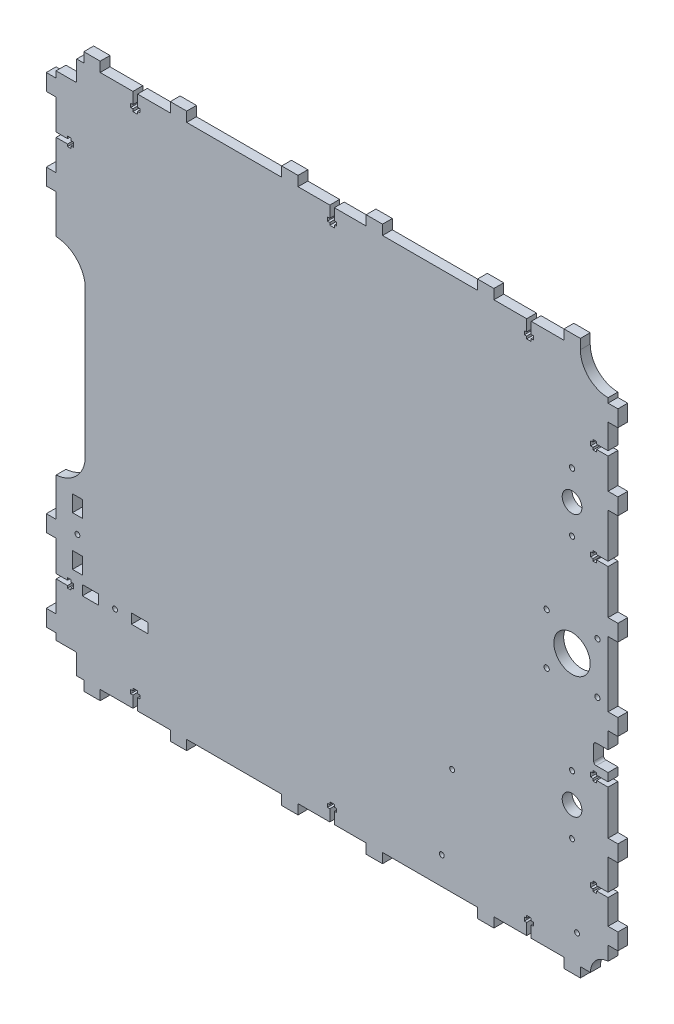
from build123d import *

# Parameters (mm, degrees)
SKETCH_1_R      = 6
SKETCH_1_R_2    = 1.6
SKETCH_1_R_3    = 1.55
SKETCH_1_R_4    = 11.1
SKETCH_1_R_5    = 1.5
SKETCH_1_W      = 10
SKETCH_1_H      = 6
SKETCH_1_W_2    = 6
SKETCH_1_H_2    = 10
EXTRUDE_1_DEPTH = 6


with BuildPart() as part:
    # Sketch 1 (on Front Plane) → Extrude 1 (new body)
    with BuildSketch(Plane.XY):
        with BuildLine():
            Line((168.199310706, -52.298122462), (168.199310706, -57.218125343))
            Line((168.199310706, -57.218125343), (161.199309499, -57.218125343))
            Line((161.199309499, -57.218125343), (161.199309499, -55.815811247))
            Line((161.199309499, -55.815811247), (158.998486916, -55.815811247))
            Line((158.998486916, -55.815811247), (158.999308988, -57.215692211))
            Line((158.999308988, -57.215692211), (157.499309247, -57.216573077))
            Line((157.499309247, -57.216573077), (157.500952992, -60.015655883))
            Line((157.500952992, -60.015655883), (159.000952734, -60.014775017))
            Line((159.000952734, -60.014775017), (159.001775414, -61.415692272))
            Line((159.001775414, -61.415692272), (161.202727499, -61.415745636))
            Line((161.202727499, -61.415745636), (161.202286063, -60.018125343))
            Line((161.202286063, -60.018125343), (168.199310706, -60.018125343))
            Line((168.199310706, -60.018125343), (168.199310706, -87.018125343))
            Line((168.199310706, -87.018125343), (174.199310706, -87.018125343))
            Line((174.199310706, -87.018125343), (174.199310706, -97.018125338))
            Line((174.199310706, -97.018125338), (168.199310706, -97.018125338))
            Line((168.199310706, -97.018125338), (168.199310706, -115.618125338))
            Line((168.199310706, -115.618125338), (161.199752595, -115.618125338))
            Line((161.199752595, -115.618125338), (161.199752595, -114.216834131))
            Line((161.199752595, -114.216834131), (158.998486916, -114.216834131))
            Line((158.998486916, -114.216834131), (158.999308988, -115.616715096))
            Line((158.999308988, -115.616715096), (157.499309247, -115.617595962))
            Line((157.499309247, -115.617595962), (157.500952992, -118.416678768))
            Line((157.500952992, -118.416678768), (159.000952734, -118.415797902))
            Line((159.000952734, -118.415797902), (159.001775414, -119.816715157))
            Line((159.001775414, -119.816715157), (161.202113772, -119.816768506))
            Line((161.202113772, -119.816768506), (161.201876481, -118.418125338))
            Line((161.201876481, -118.418125338), (168.199310706, -118.418125338))
            Line((168.199310706, -118.418125338), (168.199310706, -133.598125338))
            Line((168.199310706, -133.598125338), (174.199310706, -133.598125338))
            Line((174.199310706, -133.598125338), (174.199310706, -143.598125338))
            Line((174.199310706, -143.598125338), (168.199310706, -143.598125338))
            Line((168.199310706, -143.598125338), (168.199310706, -152.12715677))
            ThreePointArc((168.199310706, -152.12715677), (160.572403694, -155.612835394), (157.456488656, -163.398125338))
            Line((157.456488656, -163.398125338), (151.289310706, -163.398125338))
            Line((151.289310706, -163.398125338), (151.289310706, -169.398125338))
            Line((151.289310706, -169.398125338), (141.289310706, -169.398125338))
            Line((141.289310706, -169.398125338), (141.289310706, -163.398125338))
            Line((141.289310706, -163.398125338), (121.289310706, -163.398125338))
            Line((121.289310706, -163.398125338), (121.289310706, -156.4006243))
            Line((121.289310706, -156.4006243), (122.688120776, -156.400828255))
            Line((122.688120776, -156.400828255), (122.68806743, -154.200590047))
            Line((122.68806743, -154.200590047), (121.287150175, -154.199767366))
            Line((121.287150175, -154.199767366), (121.288031041, -152.699767026))
            Line((121.288031041, -152.699767026), (118.489968512, -152.69812388))
            Line((118.489968512, -152.69812388), (118.489087646, -154.198123621))
            Line((118.489087646, -154.198123621), (117.089206681, -154.197301549))
            Line((117.089206681, -154.197301549), (117.089206681, -156.398124131))
            Line((117.089206681, -156.398124131), (118.489310706, -156.398124131))
            Line((118.489310706, -156.398124131), (118.489310706, -163.398125338))
            Line((118.489310706, -163.398125338), (98.489310706, -163.398125338))
            Line((98.489310706, -163.398125338), (98.489310706, -169.398125338))
            Line((98.489310706, -169.398125338), (88.489310706, -169.398125338))
            Line((88.489310706, -169.398125338), (88.489310706, -163.398125338))
            Line((88.489310706, -163.398125338), (30.489310706, -163.398125338))
            Line((30.489310706, -163.398125338), (30.489310706, -169.398125338))
            Line((30.489310706, -169.398125338), (20.489310706, -169.398125338))
            Line((20.489310706, -169.398125338), (20.489310706, -163.398125338))
            Line((20.489310706, -163.398125338), (1.099310706, -163.398125338))
            Line((1.099310706, -163.398125338), (1.099310706, -156.4006243))
            Line((1.099310706, -156.4006243), (2.498120776, -156.400828255))
            Line((2.498120776, -156.400828255), (2.49806743, -154.200590047))
            Line((2.49806743, -154.200590047), (1.097150175, -154.199767366))
            Line((1.097150175, -154.199767366), (1.098031041, -152.699767026))
            Line((1.098031041, -152.699767026), (-1.700031488, -152.69812388))
            Line((-1.700031488, -152.69812388), (-1.700912354, -154.198123621))
            Line((-1.700912354, -154.198123621), (-3.100793319, -154.197301549))
            Line((-3.100793319, -154.197301549), (-3.100793319, -156.398124131))
            Line((-3.100793319, -156.398124131), (-1.700689294, -156.398124131))
            Line((-1.700689294, -156.398124131), (-1.700689294, -163.398125338))
            Line((-1.700689294, -163.398125338), (-21.090689294, -163.398125338))
            Line((-21.090689294, -163.398125338), (-21.090689294, -169.398125338))
            Line((-21.090689294, -169.398125338), (-31.090689294, -169.398125338))
            Line((-31.090689294, -169.398125338), (-31.090689294, -163.398125338))
            Line((-31.090689294, -163.398125338), (-89.090689294, -163.398125338))
            Line((-89.090689294, -163.398125338), (-89.090689294, -169.398125338))
            Line((-89.090689294, -169.398125338), (-99.090689294, -169.398125338))
            Line((-99.090689294, -169.398125338), (-99.090689294, -163.398125338))
            Line((-99.090689294, -163.398125338), (-119.090689294, -163.398125338))
            Line((-119.090689294, -163.398125338), (-119.090689294, -156.4006243))
            Line((-119.090689294, -156.4006243), (-117.691879224, -156.400828255))
            Line((-117.691879224, -156.400828255), (-117.69193257, -154.200590047))
            Line((-117.69193257, -154.200590047), (-119.092849825, -154.199767366))
            Line((-119.092849825, -154.199767366), (-119.091968959, -152.699767026))
            Line((-119.091968959, -152.699767026), (-121.890031488, -152.69812388))
            Line((-121.890031488, -152.69812388), (-121.890912354, -154.198123621))
            Line((-121.890912354, -154.198123621), (-123.290793319, -154.197301549))
            Line((-123.290793319, -154.197301549), (-123.290793319, -156.398124131))
            Line((-123.290793319, -156.398124131), (-121.890689294, -156.398124131))
            Line((-121.890689294, -156.398124131), (-121.890689294, -163.398125338))
            Line((-121.890689294, -163.398125338), (-141.890689294, -163.398125338))
            Line((-141.890689294, -163.398125338), (-141.890689294, -169.398125338))
            Line((-141.890689294, -169.398125338), (-151.890689294, -169.398125338))
            Line((-151.890689294, -169.398125338), (-151.890689294, -163.398125338))
            Line((-151.890689294, -163.398125338), (-156.195092631, -163.398125338))
            Line((-156.195092631, -163.398125338), (-156.195092631, -151.950559202))
            ThreePointArc((-156.195092631, -151.950559202), (-156.443252823, -151.291213387), (-157.064566439, -150.959114341))
            Line((-157.064566439, -150.959114341), (-157.195092631, -150.950559202))
            Line((-157.195092631, -150.950559202), (-168.800689294, -150.950559202))
            Line((-168.800689294, -150.950559202), (-168.800689294, -146.938125338))
            Line((-168.800689294, -146.938125338), (-174.800689294, -146.938125338))
            Line((-174.800689294, -146.938125338), (-174.800689294, -136.938125338))
            Line((-174.800689294, -136.938125338), (-168.800689294, -136.938125338))
            Line((-168.800689294, -136.938125338), (-168.800689294, -118.438125338))
            Line((-168.800689294, -118.438125338), (-161.800688087, -118.438125338))
            Line((-161.800688087, -118.438125338), (-161.800688087, -119.838229363))
            Line((-161.800688087, -119.838229363), (-159.599865505, -119.838229363))
            Line((-159.599865505, -119.838229363), (-159.600686983, -118.439360374))
            Line((-159.600686983, -118.439360374), (-158.100196827, -118.43847922))
            Line((-158.100196827, -118.43847922), (-158.095498836, -115.637580558))
            Line((-158.095498836, -115.637580558), (-159.602331088, -115.638721675))
            Line((-159.602331088, -115.638721675), (-159.603391996, -114.237804581))
            Line((-159.603391996, -114.237804581), (-161.803392384, -114.238125353))
            Line((-161.803392384, -114.238125353), (-161.803188256, -115.638125338))
            Line((-161.803188256, -115.638125338), (-168.800689294, -115.638125338))
            Line((-168.800689294, -115.638125338), (-168.800689294, -96.918125338))
            Line((-168.800689294, -96.918125338), (-174.800689294, -96.918125338))
            Line((-174.800689294, -96.918125338), (-174.800689294, -86.918125338))
            Line((-174.800689294, -86.918125338), (-168.800689294, -86.918125338))
            Line((-168.800689294, -86.918125338), (-168.800689294, -63.480258903))
            ThreePointArc((-168.800689294, -63.480258903), (-157.388702527, -58.725695754), (-151.244839154, -47.997589884))
            Line((-151.244839154, -47.997589884), (-151.272354325, 47.500944109))
            ThreePointArc((-151.272354325, 47.500944109), (-157.419219349, 58.082787741), (-168.800689294, 62.579620646))
            Line((-168.800689294, 62.579620646), (-168.800689294, 86.321874662))
            Line((-168.800689294, 86.321874662), (-174.800689294, 86.321874662))
            Line((-174.800689294, 86.321874662), (-174.800689294, 96.321874662))
            Line((-174.800689294, 96.321874662), (-168.800689294, 96.321874662))
            Line((-168.800689294, 96.321874662), (-168.800689294, 115.041874662))
            Line((-168.800689294, 115.041874662), (-161.800688087, 115.041874662))
            Line((-161.800688087, 115.041874662), (-161.800688087, 113.641770637))
            Line((-161.800688087, 113.641770637), (-159.599865505, 113.641770637))
            Line((-159.599865505, 113.641770637), (-159.600687577, 115.041651602))
            Line((-159.600687577, 115.041651602), (-158.100210407, 115.042532748))
            Line((-158.100210407, 115.042532748), (-158.102330745, 117.842414269))
            Line((-158.102330745, 117.842414269), (-159.602331088, 117.841278325))
            Line((-159.602331088, 117.841278325), (-159.603391996, 119.242195419))
            Line((-159.603391996, 119.242195419), (-161.803392384, 119.241874647))
            Line((-161.803392384, 119.241874647), (-161.803188256, 117.841874662))
            Line((-161.803188256, 117.841874662), (-168.800689294, 117.841874662))
            Line((-168.800689294, 117.841874662), (-168.800689294, 136.341874662))
            Line((-168.800689294, 136.341874662), (-174.800689294, 136.341874662))
            Line((-174.800689294, 136.341874662), (-174.800689294, 146.341874662))
            Line((-174.800689294, 146.341874662), (-168.800689294, 146.341874662))
            Line((-168.800689294, 146.341874662), (-168.800689294, 150.22196022))
            Line((-168.800689294, 150.22196022), (-157.195092631, 150.22196022))
            ThreePointArc((-157.195092631, 150.22196022), (-156.48798585, 150.514853439), (-156.195092631, 151.22196022))
            Line((-156.195092631, 151.22196022), (-156.195092631, 162.801874662))
            Line((-156.195092631, 162.801874662), (-151.890689294, 162.801874662))
            Line((-151.890689294, 162.801874662), (-151.890689294, 168.801874662))
            Line((-151.890689294, 168.801874662), (-141.890689294, 168.801874662))
            Line((-141.890689294, 168.801874662), (-141.890689294, 162.801874662))
            Line((-141.890689294, 162.801874662), (-121.890689294, 162.801874662))
            Line((-121.890689294, 162.801874662), (-121.890689294, 155.801873455))
            Line((-121.890689294, 155.801873455), (-123.290793319, 155.801873455))
            Line((-123.290793319, 155.801873455), (-123.290793319, 153.601050872))
            Line((-123.290793319, 153.601050872), (-121.890912354, 153.601872944))
            Line((-121.890912354, 153.601872944), (-121.890031488, 152.101873203))
            Line((-121.890031488, 152.101873203), (-119.091968959, 152.103516349))
            Line((-119.091968959, 152.103516349), (-119.092849825, 153.60351669))
            Line((-119.092849825, 153.60351669), (-117.69193257, 153.60433937))
            Line((-117.69193257, 153.60433937), (-117.691879224, 155.804577578))
            Line((-117.691879224, 155.804577578), (-119.090689294, 155.804373623))
            Line((-119.090689294, 155.804373623), (-119.090689294, 162.801874662))
            Line((-119.090689294, 162.801874662), (-99.090689294, 162.801874662))
            Line((-99.090689294, 162.801874662), (-99.090689294, 168.801874662))
            Line((-99.090689294, 168.801874662), (-89.090689294, 168.801874662))
            Line((-89.090689294, 168.801874662), (-89.090689294, 162.801874662))
            Line((-89.090689294, 162.801874662), (-31.090689294, 162.801874662))
            Line((-31.090689294, 162.801874662), (-31.090689294, 168.801874662))
            Line((-31.090689294, 168.801874662), (-21.090689294, 168.801874662))
            Line((-21.090689294, 168.801874662), (-21.090689294, 162.801874662))
            Line((-21.090689294, 162.801874662), (-1.700689294, 162.801874662))
            Line((-1.700689294, 162.801874662), (-1.700689294, 155.801873455))
            Line((-1.700689294, 155.801873455), (-3.100793319, 155.801873455))
            Line((-3.100793319, 155.801873455), (-3.100793319, 153.601050872))
            Line((-3.100793319, 153.601050872), (-1.700912354, 153.601872944))
            Line((-1.700912354, 153.601872944), (-1.700031488, 152.101873203))
            Line((-1.700031488, 152.101873203), (1.098031041, 152.103516349))
            Line((1.098031041, 152.103516349), (1.097150175, 153.60351669))
            Line((1.097150175, 153.60351669), (2.49806743, 153.60433937))
            Line((2.49806743, 153.60433937), (2.498120776, 155.804577578))
            Line((2.498120776, 155.804577578), (1.099310706, 155.804373623))
            Line((1.099310706, 155.804373623), (1.099310706, 162.801874662))
            Line((1.099310706, 162.801874662), (20.489310706, 162.801874662))
            Line((20.489310706, 162.801874662), (20.489310706, 168.801874662))
            Line((20.489310706, 168.801874662), (30.489310706, 168.801874662))
            Line((30.489310706, 168.801874662), (30.489310706, 162.801874662))
            Line((30.489310706, 162.801874662), (88.489310706, 162.801874662))
            Line((88.489310706, 162.801874662), (88.489310706, 168.801874662))
            Line((88.489310706, 168.801874662), (98.489310706, 168.801874662))
            Line((98.489310706, 168.801874662), (98.489310706, 162.801874662))
            Line((98.489310706, 162.801874662), (118.489310706, 162.801874662))
            Line((118.489310706, 162.801874662), (118.489310706, 155.801873455))
            Line((118.489310706, 155.801873455), (117.089206681, 155.801873455))
            Line((117.089206681, 155.801873455), (117.089206681, 153.601050872))
            Line((117.089206681, 153.601050872), (118.489087646, 153.601872944))
            Line((118.489087646, 153.601872944), (118.489968512, 152.101873203))
            Line((118.489968512, 152.101873203), (121.288031041, 152.103516349))
            Line((121.288031041, 152.103516349), (121.287150175, 153.60351669))
            Line((121.287150175, 153.60351669), (122.68806743, 153.60433937))
            Line((122.68806743, 153.60433937), (122.688120776, 155.804577578))
            Line((122.688120776, 155.804577578), (121.289310706, 155.804373623))
            Line((121.289310706, 155.804373623), (121.289310706, 162.801874662))
            Line((121.289310706, 162.801874662), (141.289310706, 162.801874662))
            Line((141.289310706, 162.801874662), (141.289310706, 168.801874662))
            Line((141.289310706, 168.801874662), (151.289310706, 168.801874662))
            Line((151.289310706, 168.801874662), (151.289310706, 162.801874662))
            ThreePointArc((151.289310706, 162.801874662), (156.242135036, 150.844698992), (168.199310706, 145.891874662))
            Line((168.199310706, 145.891874662), (168.199310706, 143.001874662))
            Line((168.199310706, 143.001874662), (174.199310706, 143.001874662))
            Line((174.199310706, 143.001874662), (174.199310706, 133.001874662))
            Line((174.199310706, 133.001874662), (168.199310706, 133.001874662))
            Line((168.199310706, 133.001874662), (168.199310706, 117.821874662))
            Line((168.199310706, 117.821874662), (161.198884876, 117.821874662))
            Line((161.198884876, 117.821874662), (161.198672593, 119.221937544))
            Line((161.198672593, 119.221937544), (158.997850029, 119.221603846))
            Line((158.997850029, 119.221603846), (158.998884357, 117.821723022))
            Line((158.998884357, 117.821723022), (157.498884767, 117.820614719))
            Line((157.498884767, 117.820614719), (157.500952921, 115.021532194))
            Line((157.500952921, 115.021532194), (159.000952512, 115.022640497))
            Line((159.000952512, 115.022640497), (159.001987605, 113.621723383))
            Line((159.001987605, 113.621723383), (161.202013777, 113.622003619))
            Line((161.202013777, 113.622003619), (161.201809668, 115.021874662))
            Line((161.201809668, 115.021874662), (168.199310706, 115.021874662))
            Line((168.199310706, 115.021874662), (168.199310706, 96.421874662))
            Line((168.199310706, 96.421874662), (174.199310706, 96.421874662))
            Line((174.199310706, 96.421874662), (174.199310706, 86.421874662))
            Line((174.199310706, 86.421874662), (168.199310706, 86.421874662))
            Line((168.199310706, 86.421874662), (168.199310706, 59.421874662))
            Line((168.199310706, 59.421874662), (161.199309232, 59.421874662))
            Line((161.199309232, 59.421874662), (161.199309232, 60.476838077))
            Line((161.199309232, 60.476838077), (158.998486738, 60.476838077))
            Line((158.998486738, 60.476838077), (158.99930881, 59.076957113))
            Line((158.99930881, 59.076957113), (157.499309069, 59.076076247))
            Line((157.499309069, 59.076076247), (157.500952814, 56.276993441))
            Line((157.500952814, 56.276993441), (159.000952556, 56.277874307))
            Line((159.000952556, 56.277874307), (159.001775236, 54.876957052))
            Line((159.001775236, 54.876957052), (161.202064095, 54.876903704))
            Line((161.202064095, 54.876903704), (161.201809668, 56.621874662))
            Line((161.201809668, 56.621874662), (168.199310706, 56.621874662))
            Line((168.199310706, 56.621874662), (168.199310706, 29.621874662))
            Line((168.199310706, 29.621874662), (174.199310706, 29.621874662))
            Line((174.199310706, 29.621874662), (174.199310706, 19.621874662))
            Line((174.199310706, 19.621874662), (168.199310706, 19.621874662))
            Line((168.199310706, 19.621874662), (168.199310706, -20.218125343))
            Line((168.199310706, -20.218125343), (174.199310706, -20.218125343))
            Line((174.199310706, -20.218125343), (174.199310706, -30.218125343))
            Line((174.199310706, -30.218125343), (168.199310706, -30.218125343))
            Line((168.199310706, -30.218125343), (168.199310706, -40.298068824))
            Line((168.199310706, -40.298068824), (160.899314476, -40.305488615))
            ThreePointArc((160.899314476, -40.305488615), (159.839101402, -40.745906282), (159.400839866, -41.807012455))
            Line((159.400839866, -41.807012455), (159.409987554, -50.807007806))
            ThreePointArc((159.409987554, -50.807007806), (159.866776617, -51.884084101), (160.958185364, -52.305482417))
            Line((160.958185364, -52.305482417), (168.199310706, -52.298122462))
        make_face()
        with Locations((146.199310706, -80.298125338)):
            Circle(SKETCH_1_R, mode=Mode.SUBTRACT)
        with Locations((130.699310706, 15.201874662)):
            Circle(SKETCH_1_R_2, mode=Mode.SUBTRACT)
        with Locations((146.199310706, 61.701874662)):
            Circle(SKETCH_1_R_3, mode=Mode.SUBTRACT)
        with Locations((161.699310706, 15.201874662)):
            Circle(SKETCH_1_R_2, mode=Mode.SUBTRACT)
        with Locations((146.199310706, -62.298125338)):
            Circle(SKETCH_1_R_3, mode=Mode.SUBTRACT)
        with Locations((161.699310706, -15.798125338)):
            Circle(SKETCH_1_R_2, mode=Mode.SUBTRACT)
        with Locations((130.699310706, -15.798125338)):
            Circle(SKETCH_1_R_2, mode=Mode.SUBTRACT)
        with Locations((146.199310706, -0.298125338)):
            Circle(SKETCH_1_R_4, mode=Mode.SUBTRACT)
        with Locations((146.199310706, 97.701874662)):
            Circle(SKETCH_1_R_2, mode=Mode.SUBTRACT)
        with Locations((146.199310706, 79.701874662)):
            Circle(SKETCH_1_R, mode=Mode.SUBTRACT)
        with Locations((-132.800689294, -116.398125338)):
            Circle(SKETCH_1_R_5, mode=Mode.SUBTRACT)
        with Locations((-155.800689294, -88.398125338)):
            Circle(SKETCH_1_R_5, mode=Mode.SUBTRACT)
        with Locations((73.019520288, -98.298125338)):
            Circle(SKETCH_1_R_5, mode=Mode.SUBTRACT)
        with Locations((66.669520288, -146.558125338)):
            Circle(SKETCH_1_R_5, mode=Mode.SUBTRACT)
        with Locations((149.249520288, -146.558125338)):
            Circle(SKETCH_1_R_5, mode=Mode.SUBTRACT)
        with Locations((146.199310706, -98.298125338)):
            Circle(SKETCH_1_R_5, mode=Mode.SUBTRACT)
        with Locations((-117.800689294, -116.398125338)):
            Rectangle(SKETCH_1_W, SKETCH_1_H, mode=Mode.SUBTRACT)
        with Locations((-147.800689294, -116.398125338)):
            Rectangle(SKETCH_1_W, SKETCH_1_H, mode=Mode.SUBTRACT)
        with Locations((-155.800689294, -73.398125338)):
            Rectangle(SKETCH_1_W_2, SKETCH_1_H_2, mode=Mode.SUBTRACT)
        with Locations((-155.800689294, -103.398125338)):
            Rectangle(SKETCH_1_W_2, SKETCH_1_H_2, mode=Mode.SUBTRACT)
    extrude(amount=EXTRUDE_1_DEPTH)


solid = part.part
